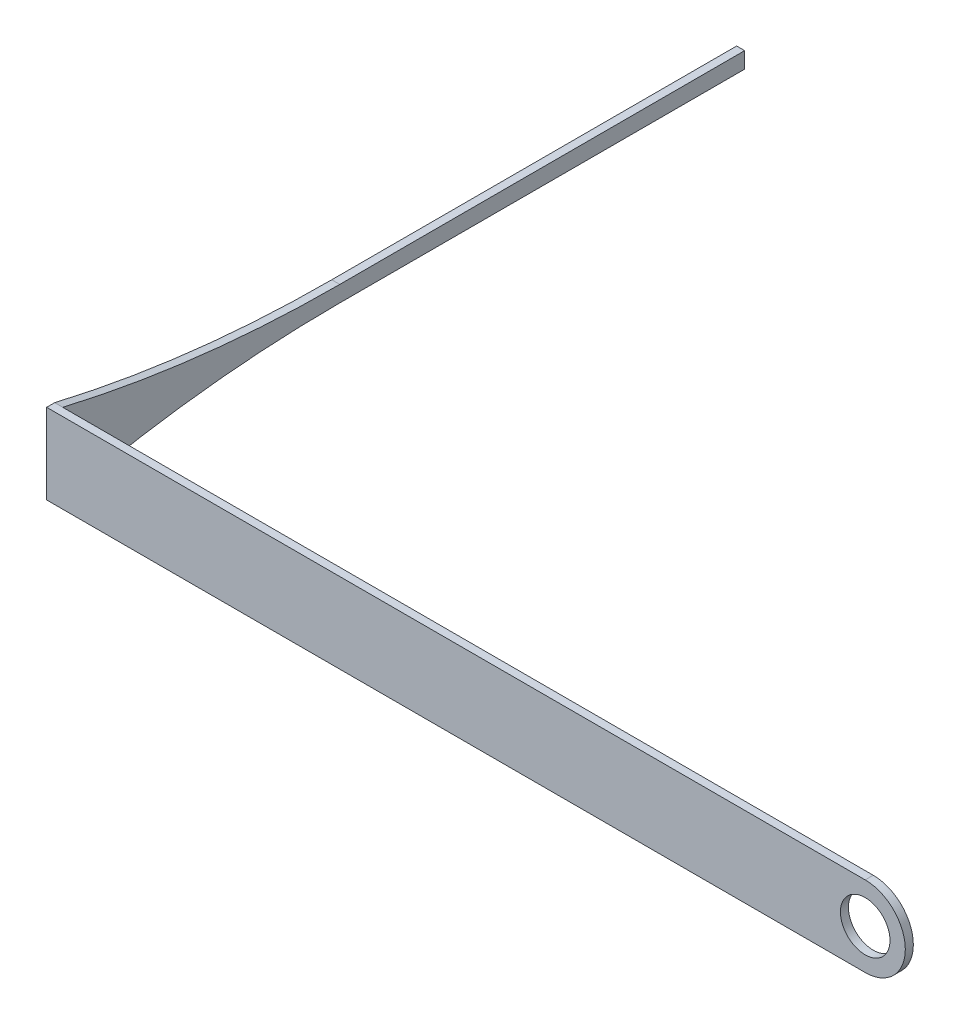
from build123d import *

# Parameters (mm, degrees)
BOSS_EXTRUDE1_DEPTH     = 5
SKETCH2_R               = 5
SKETCH2_R_2             = 3.088913235
BOSS_EXTRUDE2_DEPTH     = 1
SKETCH3_R               = 3.088913235
CUT_EXTRUDE1_DEPTH      = 1
CUT_EXTRUDE2_DEPTH      = 1
CUT_EXTRUDE2_DEPTH_BACK = 10


with BuildPart() as part:
    # Sketch1 → Boss-Extrude1 (new body, symmetric)
    with BuildSketch(Plane(origin=(0, 0, 0), x_dir=(1, 0, 0), z_dir=(0, 1, 0))):
        Polygon((0, 0), (-101, 0), (-101, 84.981911775), (-102, 84.981911775), (-102, -1), (0, -1), align=None)
    extrude(amount=BOSS_EXTRUDE1_DEPTH, both=True)

    # Sketch2 → Boss-Extrude2 (add)
    with BuildSketch(Plane.XY.offset(1)):
        Circle(SKETCH2_R)
        Circle(SKETCH2_R_2, mode=Mode.SUBTRACT)
    extrude(amount=-BOSS_EXTRUDE2_DEPTH)

    # Sketch3 → Cut-Extrude1 (cut)
    with BuildSketch(Plane.XY.offset(1)):
        Circle(SKETCH3_R)
    extrude(amount=-CUT_EXTRUDE1_DEPTH, mode=Mode.SUBTRACT)

    # Sketch4 → Cut-Extrude2 (cut, two sides)
    with BuildSketch(Plane.ZY.offset(102)) as cut_extrude2_sk:
        with BuildLine():
            Line((-84.981911775, 5), (-84.981911775, 1))
            Line((-84.981911775, 1), (-34.527427825, 1))
            ThreePointArc((-34.527427825, 1), (-17.14825011, 2.003332972), (0, 5))
            Line((0, 5), (-84.981911775, 5))
        make_face()
        with BuildLine():
            Line((-34.527427825, -1), (-84.981911775, -1))
            Line((-84.981911775, -1), (-84.981911775, -5))
            Line((-84.981911775, -5), (0, -5))
            ThreePointArc((0, -5), (-17.14825011, -2.003332972), (-34.527427825, -1))
        make_face()
    extrude(amount=CUT_EXTRUDE2_DEPTH, mode=Mode.SUBTRACT)
    extrude(cut_extrude2_sk.sketch, amount=-CUT_EXTRUDE2_DEPTH_BACK, mode=Mode.SUBTRACT)


solid = part.part
